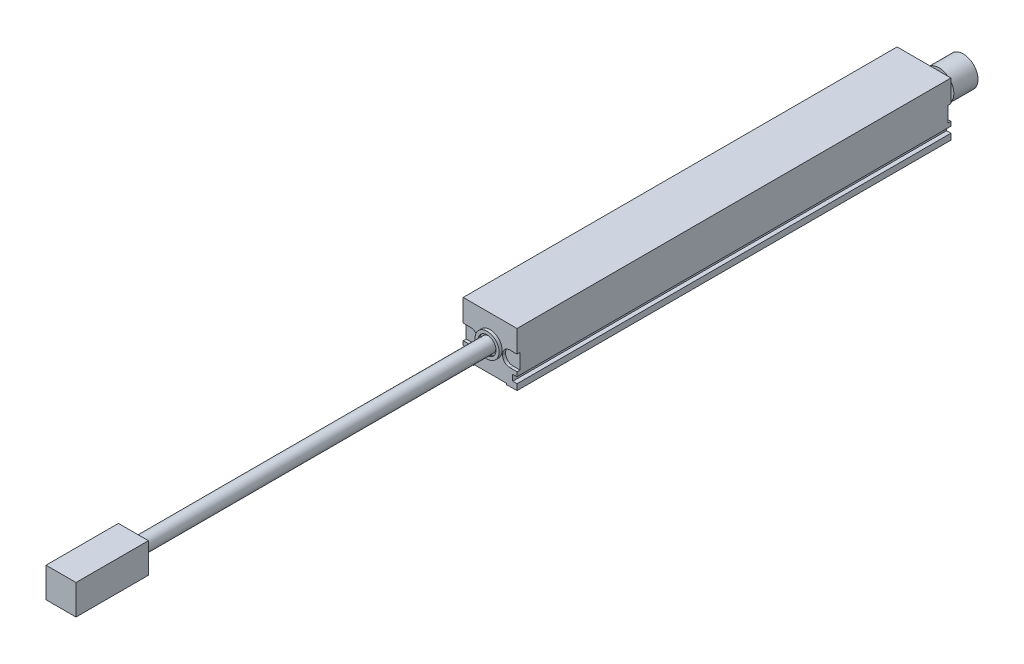
from build123d import *

# Parameters (mm, degrees)
CROQUIS1_W              = 17.8
CROQUIS1_H              = 17.82
SALIENTE_EXTRUIR1_DEPTH = 143.52
CROQUIS2_W              = 11
CROQUIS2_H              = 143.52
CORTAR_EXTRUIR1_DEPTH   = 0.38
CROQUIS3_W              = 1.42
CROQUIS3_H              = 2
CORTAR_EXTRUIR2_DEPTH   = 144.52
CROQUIS4_W              = 4.77
CROQUIS4_H              = 5.05
CORTAR_EXTRUIR3_DEPTH   = 1
CORTAR_EXTRUIR4_START   = -142.52
CROQUIS5_W              = 4.77
CROQUIS5_H              = 5.05
CORTAR_EXTRUIR4_DEPTH   = 1
REDONDEO1_R             = 2.385
REDONDEO2_R             = 2.385
REDONDEO3_R             = 2.385
REDONDEO4_R             = 2.385
REDONDEO5_R             = 2.385
REDONDEO6_R             = 2.385
REDONDEO7_R             = 2.385
REDONDEO8_R             = 2.385
CROQUIS6_R              = 3.975
SALIENTE_EXTRUIR2_DEPTH = 1
CROQUIS7_R              = 2.95
CORTAR_EXTRUIR5_DEPTH   = 0.5
CROQUIS8_R              = 2.4
SALIENTE_EXTRUIR3_DEPTH = 117.49
SALIENTE_EXTRUIR4_DEPTH = 23.95
CROQUIS10_R             = 3.185
SALIENTE_EXTRUIR5_DEPTH = 4.95
CROQUIS15_R             = 4.92
SALIENTE_EXTRUIR6_DEPTH = 8


with BuildPart() as part:
    # Croquis1 → Saliente-Extruir1 (new body)
    with BuildSketch(Plane.XY):
        with Locations((8.9, 8.91)):
            Rectangle(CROQUIS1_W, CROQUIS1_H)
    extrude(amount=SALIENTE_EXTRUIR1_DEPTH)

    # Croquis2 → Cortar-Extruir1 (cut)
    with BuildSketch(Plane.XZ):
        with Locations((8.9, 71.76)):
            Rectangle(CROQUIS2_W, CROQUIS2_H)
    extrude(amount=-CORTAR_EXTRUIR1_DEPTH, mode=Mode.SUBTRACT)

    # Croquis3 → Cortar-Extruir2 (cut, through all)
    with BuildSketch(Plane(origin=(0, 0, 0), x_dir=(-1, 0, 0), z_dir=(0, 0, -1))):
        with Locations((-17.09, 3)):
            Rectangle(CROQUIS3_W, CROQUIS3_H)
        with Locations((-0.71, 3)):
            Rectangle(CROQUIS3_W, CROQUIS3_H)
    extrude(amount=-CORTAR_EXTRUIR2_DEPTH, mode=Mode.SUBTRACT)

    # Croquis4 → Cortar-Extruir3 (cut)
    with BuildSketch(Plane(origin=(0, 0, 0), x_dir=(-1, 0, 0), z_dir=(0, 0, -1))):
        with Locations((-2.385, 7.945)):
            Rectangle(CROQUIS4_W, CROQUIS4_H)
        with Locations((-15.415, 7.945)):
            Rectangle(CROQUIS4_W, CROQUIS4_H)
    extrude(amount=-CORTAR_EXTRUIR3_DEPTH, mode=Mode.SUBTRACT)

    # Croquis5 → Cortar-Extruir4 (cut)
    with BuildSketch(Plane(origin=(0, 0, 1), x_dir=(-1, 0, 0), z_dir=(0, 0, -1)).offset(CORTAR_EXTRUIR4_START)):
        with Locations((-15.415, 7.945)):
            Rectangle(CROQUIS5_W, CROQUIS5_H)
        with Locations((-2.385, 7.945)):
            Rectangle(CROQUIS5_W, CROQUIS5_H)
    extrude(amount=CORTAR_EXTRUIR4_DEPTH, mode=Mode.SUBTRACT)

    # Redondeo1
    redondeo1_edges = [part.edges().sort_by_distance(p)[0] for p in [
        (4.77, 5.42, 0.5),
    ]]
    fillet(redondeo1_edges, radius=REDONDEO1_R)

    # Redondeo2
    redondeo2_edges = [part.edges().sort_by_distance(p)[0] for p in [
        (4.77, 10.47, 0.5),
    ]]
    fillet(redondeo2_edges, radius=REDONDEO2_R)

    # Redondeo3
    redondeo3_edges = [part.edges().sort_by_distance(p)[0] for p in [
        (13.03, 10.47, 0.5),
    ]]
    fillet(redondeo3_edges, radius=REDONDEO3_R)

    # Redondeo4
    redondeo4_edges = [part.edges().sort_by_distance(p)[0] for p in [
        (13.03, 5.42, 0.5),
    ]]
    fillet(redondeo4_edges, radius=REDONDEO4_R)

    # Redondeo5
    redondeo5_edges = [part.edges().sort_by_distance(p)[0] for p in [
        (13.03, 10.47, 143.02),
    ]]
    fillet(redondeo5_edges, radius=REDONDEO5_R)

    # Redondeo6
    redondeo6_edges = [part.edges().sort_by_distance(p)[0] for p in [
        (13.03, 5.42, 143.02),
    ]]
    fillet(redondeo6_edges, radius=REDONDEO6_R)

    # Redondeo7
    redondeo7_edges = [part.edges().sort_by_distance(p)[0] for p in [
        (4.77, 5.42, 143.02),
    ]]
    fillet(redondeo7_edges, radius=REDONDEO7_R)

    # Redondeo8
    redondeo8_edges = [part.edges().sort_by_distance(p)[0] for p in [
        (4.77, 10.47, 143.02),
    ]]
    fillet(redondeo8_edges, radius=REDONDEO8_R)

    # Croquis6 → Saliente-Extruir2 (add)
    with BuildSketch(Plane.XY.offset(143.52)):
        with Locations((8.9, 9.1)):
            Circle(CROQUIS6_R)
    extrude(amount=SALIENTE_EXTRUIR2_DEPTH)

    # Croquis7 → Cortar-Extruir5 (cut)
    with BuildSketch(Plane.XY.offset(144.52)):
        with Locations((8.9, 9.1)):
            Circle(CROQUIS7_R)
    extrude(amount=-CORTAR_EXTRUIR5_DEPTH, mode=Mode.SUBTRACT)

    # Croquis8 → Saliente-Extruir3 (add)
    with BuildSketch(Plane.XY.offset(144.02)):
        with Locations((8.9, 9.1)):
            Circle(CROQUIS8_R)
    extrude(amount=SALIENTE_EXTRUIR3_DEPTH)

    # Croquis9 → Saliente-Extruir4 (add)
    with BuildSketch(Plane.XY.offset(261.51)):
        with BuildLine():
            Line((3.94, 4.145), (8.9, 4.145))
            Line((8.9, 4.145), (8.9, 6.7))
            ThreePointArc((8.9, 6.7), (6.5, 9.1), (8.9, 11.5))
            Line((8.9, 11.5), (8.9, 14.055))
            Line((8.9, 14.055), (3.94, 14.055))
            Line((3.94, 14.055), (3.94, 4.145))
        make_face()
        with BuildLine():
            Line((8.9, 6.7), (8.9, 4.145))
            Line((8.9, 4.145), (13.86, 4.145))
            Line((13.86, 4.145), (13.86, 14.055))
            Line((13.86, 14.055), (8.9, 14.055))
            Line((8.9, 14.055), (8.9, 11.5))
            ThreePointArc((8.9, 11.5), (10.597056275, 10.797056275), (11.3, 9.1))
            ThreePointArc((11.3, 9.1), (10.597056275, 7.402943725), (8.9, 6.7))
        make_face()
        with BuildLine():
            ThreePointArc((8.9, 11.5), (6.5, 9.1), (8.9, 6.7))
            Line((8.9, 6.7), (8.9, 11.5))
        make_face()
        with BuildLine():
            Line((8.9, 11.5), (8.9, 6.7))
            ThreePointArc((8.9, 6.7), (10.597056275, 7.402943725), (11.3, 9.1))
            ThreePointArc((11.3, 9.1), (10.597056275, 10.797056275), (8.9, 11.5))
        make_face()
    extrude(amount=SALIENTE_EXTRUIR4_DEPTH)

    # Croquis10 → Saliente-Extruir5 (add)
    with BuildSketch(Plane(origin=(0, 0, 0), x_dir=(-1, 0, 0), z_dir=(0, 0, -1))):
        with Locations((-8.9, 8.91)):
            Circle(CROQUIS10_R)
    extrude(amount=SALIENTE_EXTRUIR5_DEPTH)

    # Croquis15 → Saliente-Extruir6 (add)
    with BuildSketch(Plane(origin=(0, 0, -4.95), x_dir=(-1, 0, 0), z_dir=(0, 0, -1))):
        with Locations((-8.9, 8.91)):
            Circle(CROQUIS15_R)
    extrude(amount=SALIENTE_EXTRUIR6_DEPTH)


solid = part.part
